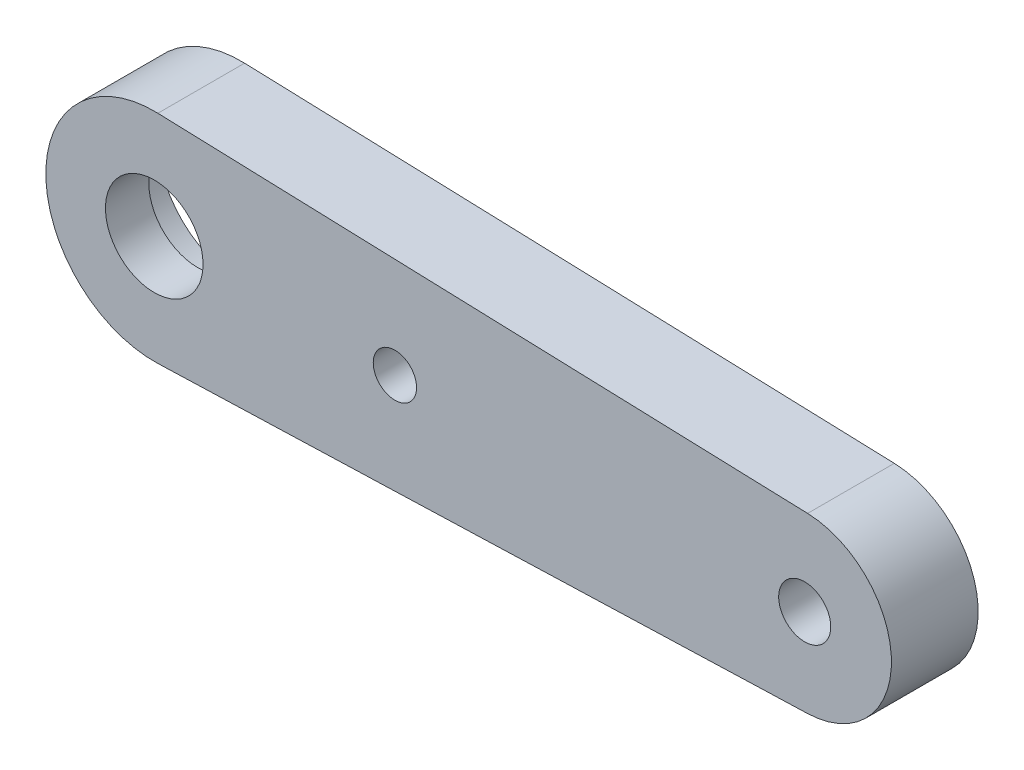
from build123d import *
from build123d.topology import SkipClean

# Parameters (mm, degrees)
SKETCH14_R          = 4
SKETCH14_R_2        = 1.2
SKETCH14_R_3        = 5
BOSS_EXTRUDE1_DEPTH = 4
CUT_EXTRUDE1_START  = -2.5
SKETCH15_R          = 1.2
CUT_EXTRUDE1_DEPTH  = 1.5
CUT_EXTRUDE2_DEPTH  = 0.5
SKETCH17_R          = 1
CUT_EXTRUDE3_DEPTH  = 6
SKETCH18_R          = 2.25
CUT_EXTRUDE4_DEPTH  = 10


with BuildPart() as part:
    # Sketch14 → Boss-Extrude1 (new body)
    with BuildSketch(Plane.XY):
        with BuildLine():
            Line((30.133333333, 3.99777716), (0.166666667, 4.99722145))
            ThreePointArc((0.166666667, 4.99722145), (3.593976442, 3.476108936), (5, 0))
            ThreePointArc((5, 0), (3.593976442, -3.476108936), (0.166666667, -4.99722145))
            Line((0.166666667, -4.99722145), (30.133333333, -3.99777716))
            ThreePointArc((30.133333333, -3.99777716), (26, 0), (30.133333333, 3.99777716))
        make_face()
        with Locations((30, 0)):
            Circle(SKETCH14_R)
        with Locations((30, 0)):
            Circle(SKETCH14_R_2, mode=Mode.SUBTRACT)
        Circle(SKETCH14_R_3)
        Circle(SKETCH14_R_2, mode=Mode.SUBTRACT)
    extrude(amount=BOSS_EXTRUDE1_DEPTH)

    # Sketch15 → Cut-Extrude1 (cut)
    with BuildSketch(Plane.XY.offset(4).offset(CUT_EXTRUDE1_START)):
        with BuildLine():
            Line((16.121698113, 2.33951917), (0.363207547, 3.832829278))
            ThreePointArc((0.363207547, 3.832829278), (-3.85, 0), (0.363207547, -3.832829278))
            Line((0.363207547, -3.832829278), (16.121698113, -2.33951917))
            ThreePointArc((16.121698113, -2.33951917), (18.25, 0), (16.121698113, 2.33951917))
        make_face()
        Circle(SKETCH15_R, mode=Mode.SUBTRACT)
    extrude(amount=-CUT_EXTRUDE1_DEPTH, mode=Mode.SUBTRACT)

    # Sketch16 → Cut-Extrude2 (cut)
    with SkipClean():  # the faces are left unmerged after this step: merging them gives an invalid solid
        with BuildSketch(Plane(origin=(0, 0, 1.5), x_dir=(-1, 0, 0), z_dir=(0, 0, -1))):
            with BuildLine():
                ThreePointArc((-0.363207547, -3.832829278), (-3.85, 0), (-0.363207547, 3.832829278))
                Line((-0.363207547, 3.832829278), (-6, 3.298674112))
                Line((-6, 3.298674112), (-6, -3.298674112))
                Line((-6, -3.298674112), (-0.363207547, -3.832829278))
            make_face()
            with BuildLine():
                ThreePointArc((3.85, 0), (2.722361108, 2.722361108), (0, 3.85))
                Line((0, 3.85), (0, 1.2))
                ThreePointArc((0, 1.2), (0.848528137, 0.848528137), (1.2, 0))
                ThreePointArc((1.2, 0), (0.848528137, -0.848528137), (0, -1.2))
                Line((0, -1.2), (0, -3.85))
                ThreePointArc((0, -3.85), (2.722361108, -2.722361108), (3.85, 0))
            make_face()
            with BuildLine():
                Line((0, 1.2), (0, 3.85))
                ThreePointArc((0, 3.85), (-0.181806598, 3.845704924), (-0.363207547, 3.832829278))
                ThreePointArc((-0.363207547, 3.832829278), (-3.85, 0), (-0.363207547, -3.832829278))
                ThreePointArc((-0.363207547, -3.832829278), (-0.181806598, -3.845704924), (0, -3.85))
                Line((0, -3.85), (0, -1.2))
                ThreePointArc((0, -1.2), (-1.2, 0), (0, 1.2))
            make_face()
        extrude(amount=-CUT_EXTRUDE2_DEPTH, mode=Mode.SUBTRACT)

    # Sketch17 → Cut-Extrude3 (cut)
    with SkipClean():  # the faces are left unmerged after this step: merging them gives an invalid solid
        with BuildSketch(Plane(origin=(0, 0, 1.5), x_dir=(-1, 0, 0), z_dir=(0, 0, -1))):
            with Locations((-11.1, 0)):
                Circle(SKETCH17_R)
        extrude(amount=-CUT_EXTRUDE3_DEPTH, mode=Mode.SUBTRACT)

    # Sketch18 → Cut-Extrude4 (cut)
    with SkipClean():  # the faces are left unmerged after this step: merging them gives an invalid solid
        with BuildSketch(Plane.XY.offset(4)):
            Circle(SKETCH18_R)
        extrude(amount=-CUT_EXTRUDE4_DEPTH, mode=Mode.SUBTRACT)


solid = part.part
